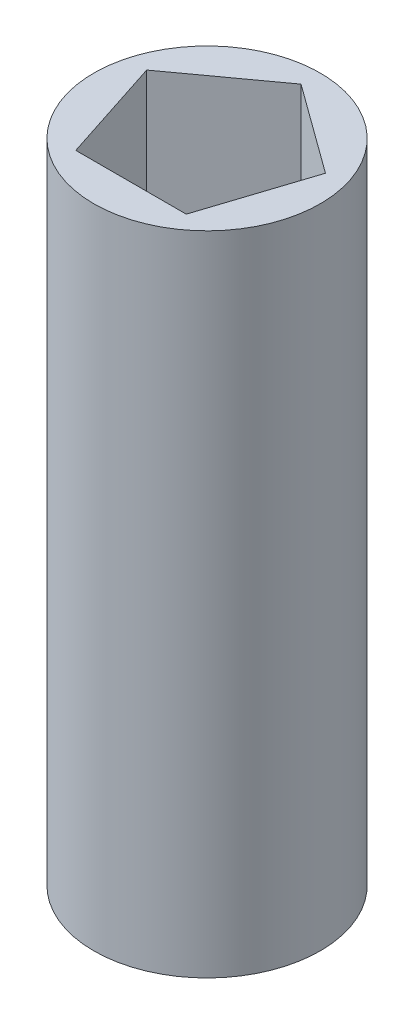
from build123d import *

# Parameters (mm, degrees)
SKETCH1_R           = 3.5
BOSS_EXTRUDE1_DEPTH = 20


with BuildPart() as part:
    # Sketch1 → Boss-Extrude1 (new body)
    with BuildSketch(Plane(origin=(0, 0, 0), x_dir=(1, 0, 0), z_dir=(0, 1, 0))):
        Circle(SKETCH1_R)
        Polygon((1.707374941, -2.35), (2.762590686, 0.897620126), (0, 2.904759747), (-2.762590686, 0.897620126), (-1.707374941, -2.35), align=None, mode=Mode.SUBTRACT)
    extrude(amount=BOSS_EXTRUDE1_DEPTH)


solid = part.part
